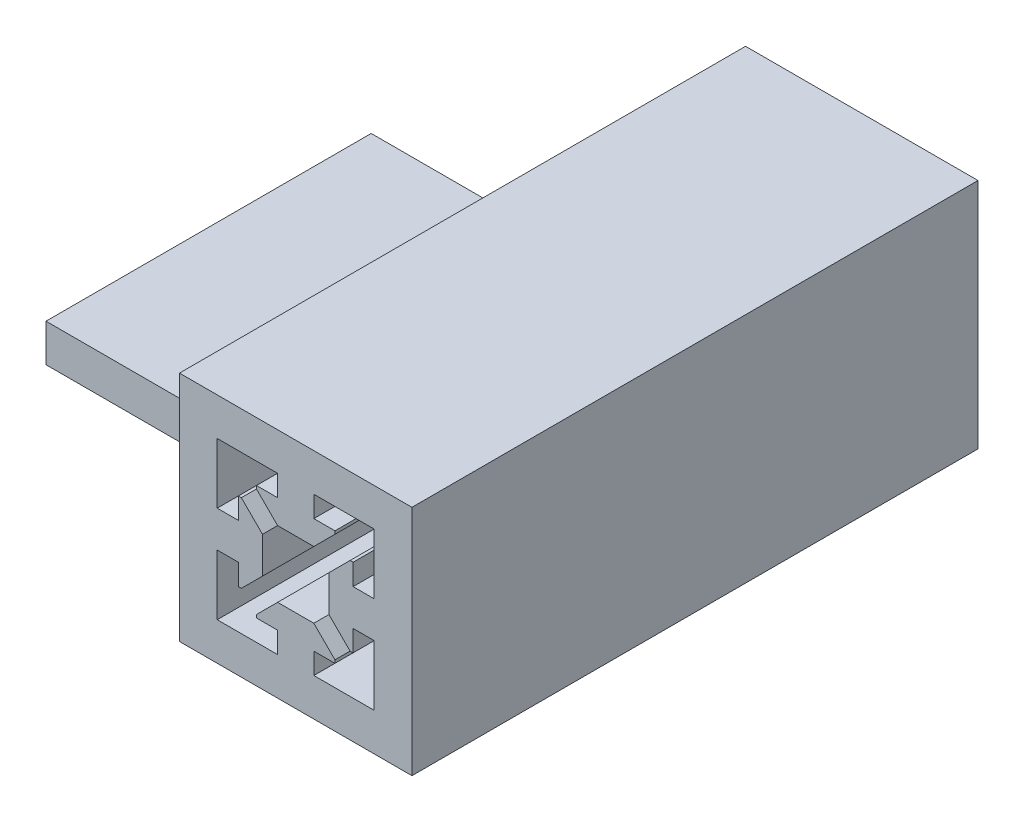
from build123d import *

# Parameters (mm, degrees)
EXTRUDE_START   = 13
SKETCH_1_W      = 30.8
SKETCH_1_H      = 30.8
EXTRUDE_1_DEPTH = 75
SKETCH_3_W      = 43.086164537
SKETCH_3_H      = 5
EXTRUDE_2_DEPTH = 40.6


with BuildPart() as part:
    # ｽｹｯﾁ1 → ﾎﾞｽ - 押し出し1 (new body)
    with BuildSketch(Plane.XY.offset(EXTRUDE_START)):
        with Locations((56, 18.4)):
            Rectangle(SKETCH_1_W, SKETCH_1_H)
        Polygon((53.6, 26.002672003), (53.6, 28.8), (45.6, 28.8), (45.6, 20.8), (48.397327997, 20.8), (48.397327997, 23.6), (48.797327997, 23.6), (51.597327997, 20.8), (51.597327997, 16), (48.797327997, 13.2), (48.397327997, 13.2), (48.397327997, 16), (45.6, 16), (45.6, 8), (53.6, 8), (53.6, 10.797327997), (50.8, 10.797327997), (50.8, 11.197327997), (53.6, 13.997327997), (58.4, 13.997327997), (61.2, 11.197327997), (61.2, 10.797327997), (58.4, 10.797327997), (58.4, 8), (66.4, 8), (66.4, 16), (63.602672003, 16), (63.602672003, 13.2), (63.202672003, 13.2), (60.402672003, 16), (60.402672003, 20.8), (63.202672003, 23.6), (63.602672003, 23.6), (63.602672003, 20.8), (66.4, 20.8), (66.4, 28.8), (58.4, 28.8), (58.4, 26.002672003), (61.2, 26.002672003), (61.2, 25.602672003), (58.4, 22.802672003), (53.6, 22.802672003), (50.8, 25.602672003), (50.8, 26.002672003), align=None, mode=Mode.SUBTRACT)
    extrude(amount=EXTRUDE_1_DEPTH)

    # ｽｹｯﾁ3 → ﾎﾞｽ - 押し出し2 (add)
    with BuildSketch(Plane.ZY.offset(-40.6)):
        with Locations((43.543082269, 5.5)):
            Rectangle(SKETCH_3_W, SKETCH_3_H)
    extrude(amount=EXTRUDE_2_DEPTH)


solid = part.part
